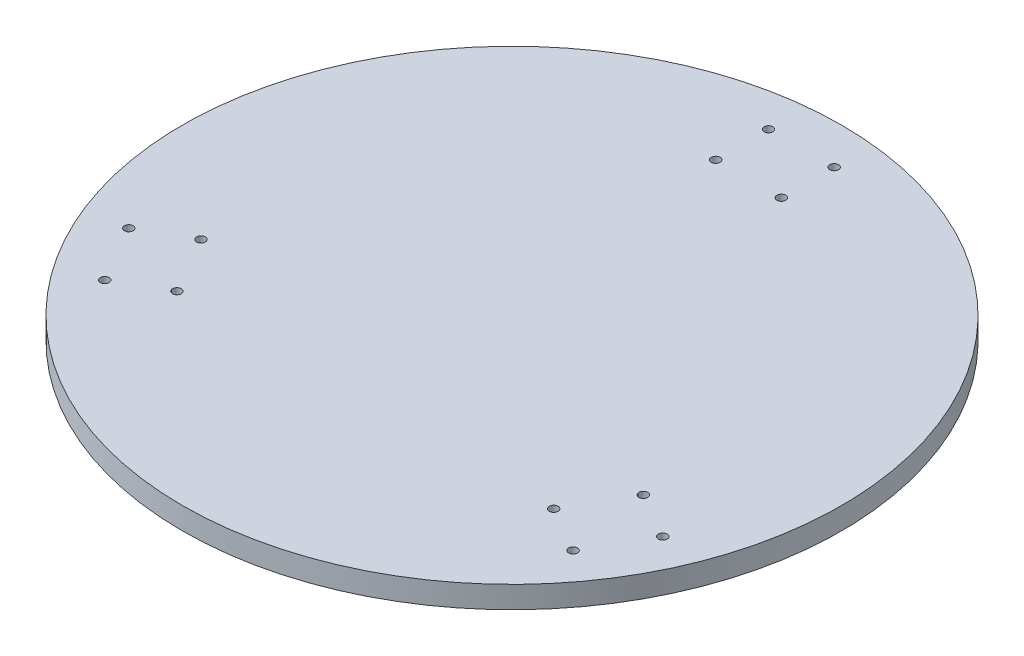
from build123d import *

# Parameters (mm, degrees)
SKETCH1_R           = 150
BOSS_EXTRUDE1_DEPTH = 10
SKETCH2_R           = 2
CUT_EXTRUDE1_DEPTH  = 10


with BuildPart() as part:
    # Sketch1 → Boss-Extrude1 (new body)
    with BuildSketch(Plane(origin=(0, 0, 0), x_dir=(1, 0, 0), z_dir=(0, 1, 0))):
        Circle(SKETCH1_R)
    extrude(amount=BOSS_EXTRUDE1_DEPTH)

    # Sketch2 → Cut-Extrude1 (cut)
    with BuildSketch(Plane(origin=(0, 10, 0), x_dir=(1, 0, 0), z_dir=(0, 1, 0))):
        with Locations((-14.945, 131.706442493)):
            Circle(SKETCH2_R)
        with Locations((-14.945, 107.646442493)):
            Circle(SKETCH2_R)
        with Locations((14.945, 107.646442493)):
            Circle(SKETCH2_R)
        with Locations((14.945, 131.706442493)):
            Circle(SKETCH2_R)
        with Locations((85.752053826, -66.765970906)):
            Circle(SKETCH2_R)
        with Locations((100.697053826, -40.880471587)):
            Circle(SKETCH2_R)
        with Locations((106.588625041, -78.795970906)):
            Circle(SKETCH2_R)
        with Locations((121.533625041, -52.910471587)):
            Circle(SKETCH2_R)
        with Locations((-100.697053826, -40.880471587)):
            Circle(SKETCH2_R)
        with Locations((-85.752053826, -66.765970906)):
            Circle(SKETCH2_R)
        with Locations((-121.533625041, -52.910471587)):
            Circle(SKETCH2_R)
        with Locations((-106.588625041, -78.795970906)):
            Circle(SKETCH2_R)
    extrude(amount=-CUT_EXTRUDE1_DEPTH, mode=Mode.SUBTRACT)


solid = part.part
